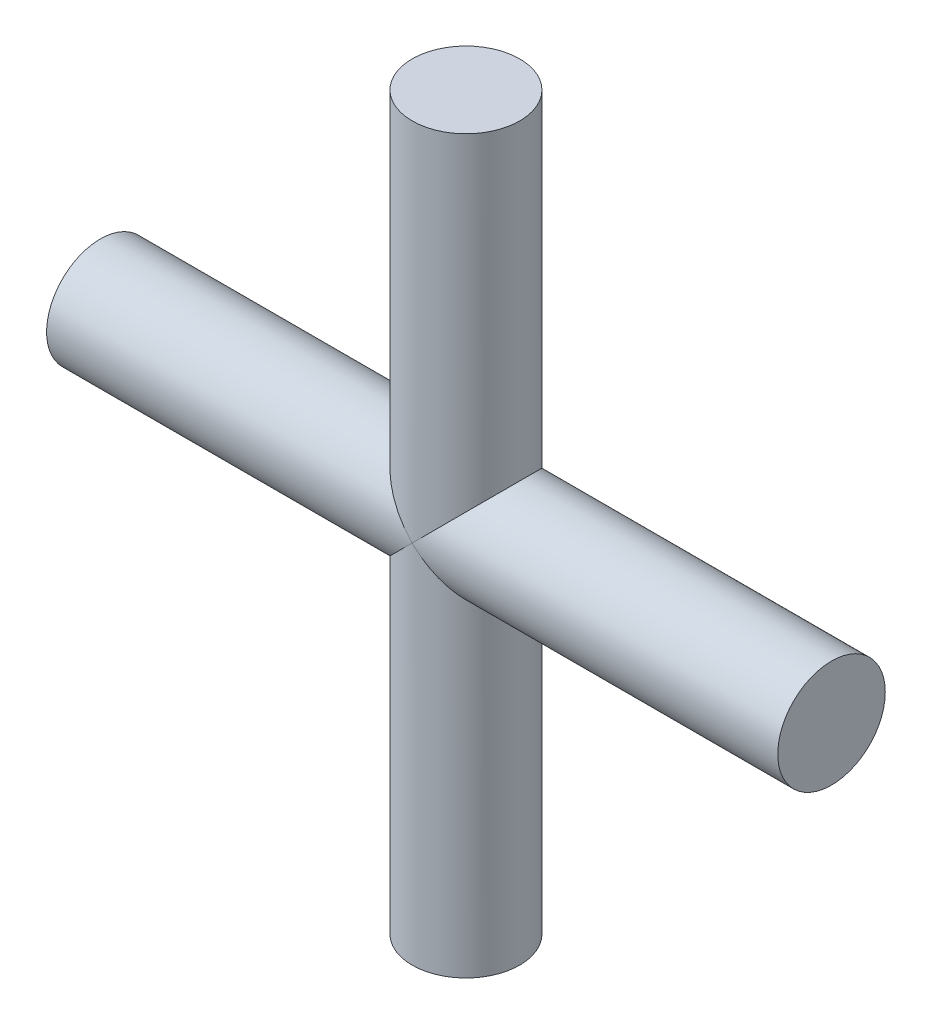
from build123d import *

# Parameters (mm, degrees)
SKETCH2_R           = 2.5
BOSS_EXTRUDE1_DEPTH = 34
SKETCH3_R           = 2.5
BOSS_EXTRUDE2_DEPTH = 17


with BuildPart() as part:
    # Sketch2 → Boss-Extrude1 (new body)
    with BuildSketch(Plane(origin=(0, 0, 0), x_dir=(1, 0, 0), z_dir=(0, 1, 0))):
        Circle(SKETCH2_R)
    extrude(amount=BOSS_EXTRUDE1_DEPTH)

    # Sketch3 → Boss-Extrude2 (add, symmetric)
    with BuildSketch(Plane(origin=(0, 0, 0), x_dir=(0, 0, -1), z_dir=(1, 0, 0))):
        with Locations((0, 17)):
            Circle(SKETCH3_R)
    extrude(amount=BOSS_EXTRUDE2_DEPTH, both=True)


solid = part.part
